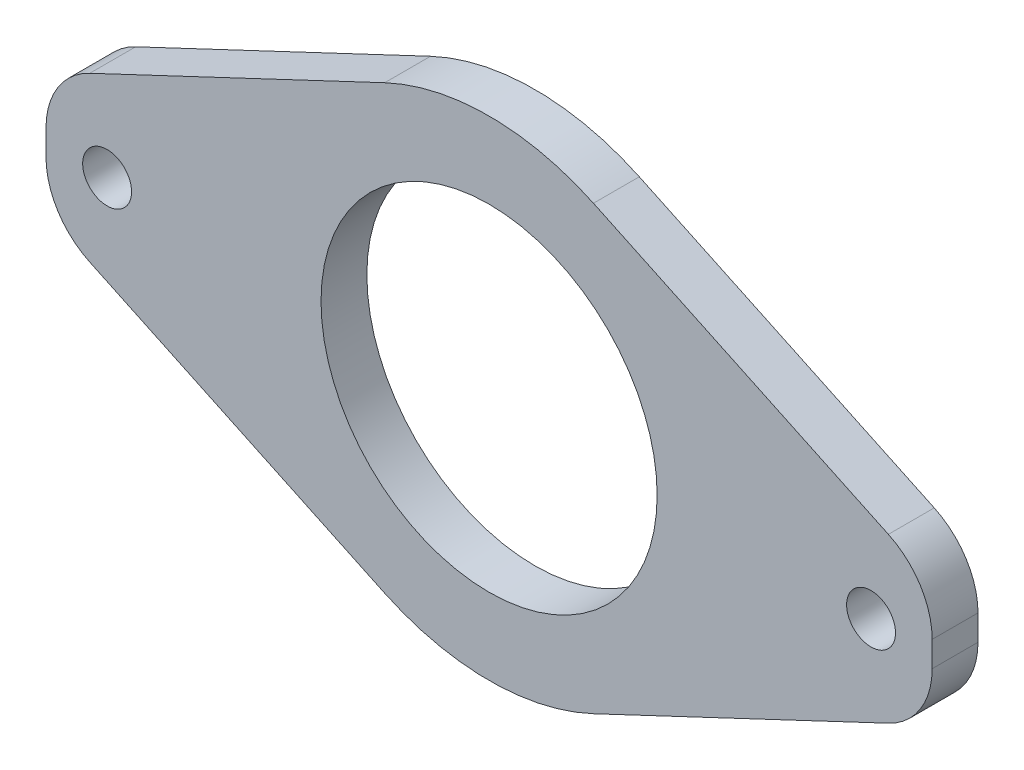
from build123d import *

# Parameters (mm, degrees)
ESBO_O1_R                = 11
ESBO_O1_R_2              = 1.6
RESSALTO_EXTRUS_O1_DEPTH = 3
FILETE1_R                = 5


with BuildPart() as part:
    # Esboço1 → Ressalto-extrusão1 (new body)
    with BuildSketch(Plane.XY):
        with BuildLine():
            Line((-15.491933385, -4), (-29, -4))
            Line((-29, -4), (-6.831996166, -14.468027799))
            ThreePointArc((-6.831996166, -14.468027799), (-12.328193669, -10.198805854), (-15.491933385, -4))
        make_face()
        with BuildLine():
            Line((-29, -4), (-15.491933385, -4))
            ThreePointArc((-15.491933385, -4), (0, -16), (15.491933385, -4))
            Line((15.491933385, -4), (29, -4))
            Line((29, -4), (29, 4))
            Line((29, 4), (15.491933385, 4))
            ThreePointArc((15.491933385, 4), (0, 16), (-15.491933385, 4))
            Line((-15.491933385, 4), (-29, 4))
            Line((-29, 4), (-29, -4))
        make_face()
        Circle(ESBO_O1_R, mode=Mode.SUBTRACT)
        with Locations((-25, 0)):
            Circle(ESBO_O1_R_2, mode=Mode.SUBTRACT)
        with Locations((25, 0)):
            Circle(ESBO_O1_R_2, mode=Mode.SUBTRACT)
        with BuildLine():
            Line((-6.831996166, 14.468027799), (-29, 4))
            Line((-29, 4), (-15.491933385, 4))
            ThreePointArc((-15.491933385, 4), (-12.328193669, 10.198805854), (-6.831996166, 14.468027799))
        make_face()
        with BuildLine():
            ThreePointArc((15.491933385, -4), (12.328193669, -10.198805854), (6.831996166, -14.468027799))
            Line((6.831996166, -14.468027799), (29, -4))
            Line((29, -4), (15.491933385, -4))
        make_face()
        with BuildLine():
            Line((29, 4), (6.831996166, 14.468027799))
            ThreePointArc((6.831996166, 14.468027799), (12.328193669, 10.198805854), (15.491933385, 4))
            Line((15.491933385, 4), (29, 4))
        make_face()
    extrude(amount=RESSALTO_EXTRUS_O1_DEPTH)

    # Filete1
    filete1_edges = [part.edges().sort_by_distance(p)[0] for p in [
        (29, 4, 1.5),
        (29, -4, 1.5),
        (-29, -4, 1.5),
        (-29, 4, 1.5),
    ]]
    fillet(filete1_edges, radius=FILETE1_R)


solid = part.part
